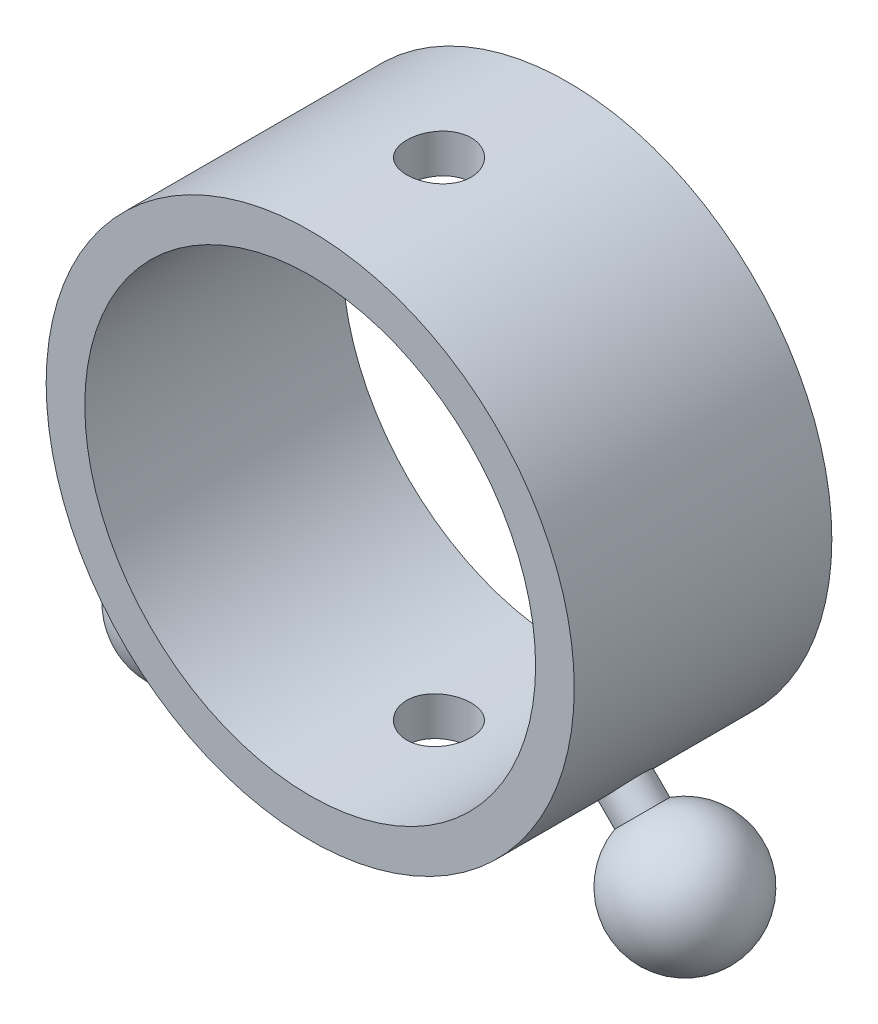
from build123d import *

# Parameters (mm, degrees)
SKETCH1_R               = 20.5
SKETCH1_R_2             = 17.5
BOSS_EXTRUDE1_DEPTH     = 20
SKETCH2_R               = 2.5
CUT_EXTRUDE1_DEPTH      = 21.5
CUT_EXTRUDE1_DEPTH_BACK = 21.5


with BuildPart() as part:
    # Sketch1 → Boss-Extrude1 (new body)
    with BuildSketch(Plane.XY):
        Circle(SKETCH1_R)
        Circle(SKETCH1_R_2, mode=Mode.SUBTRACT)
    extrude(amount=BOSS_EXTRUDE1_DEPTH)

    # Sketch2 → Cut-Extrude1 (cut, two sides)
    with BuildSketch(Plane(origin=(0, 0, 0), x_dir=(1, 0, 0), z_dir=(0, 1, 0))) as cut_extrude1_sk:
        with Locations((0, -10)):
            Circle(SKETCH2_R)
    extrude(amount=CUT_EXTRUDE1_DEPTH, mode=Mode.SUBTRACT)
    extrude(cut_extrude1_sk.sketch, amount=-CUT_EXTRUDE1_DEPTH_BACK, mode=Mode.SUBTRACT)

    # Sketch4 → Revolve1 (revolve)
    with BuildSketch(Plane(origin=(0, 0, 10), x_dir=(-1, 0, 0), z_dir=(0, 0, -1))):
        with BuildLine():
            Line((14.142135624, -14.142135624), (22.627416998, -22.627416998))
            ThreePointArc((22.627416998, -22.627416998), (16.241444529, -23.199802273), (14.5425359, -17.017409634))
            Line((14.5425359, -17.017409634), (12.904698757, -15.379572491))
            Line((12.904698757, -15.379572491), (14.142135624, -14.142135624))
        make_face()
    revolve1 = revolve(axis=Axis((-14.142135624, -14.142135624, 10), (-0.707106781, -0.707106781, 0)))

    # Mirror1: Revolve1 across plane
    add(revolve1.mirror(Plane(origin=(0, 0, 0), x_dir=(0, 0, 1), z_dir=(1, 0, 0))))


solid = part.part
